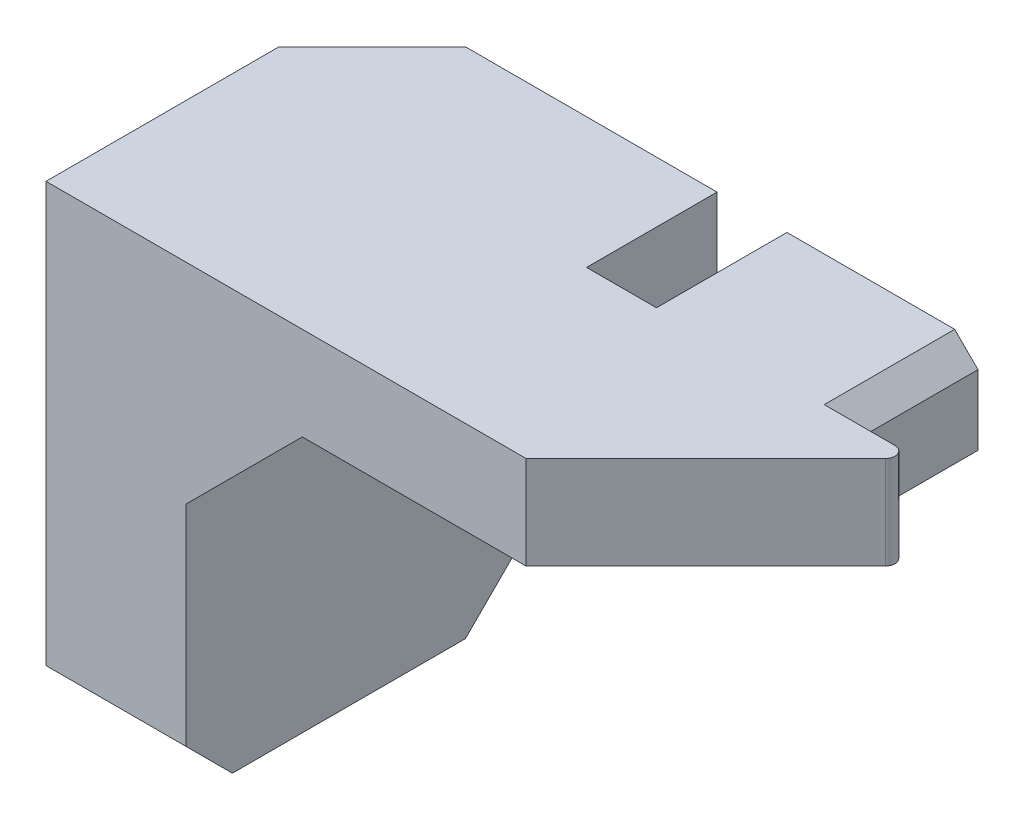
from build123d import *

# Parameters (mm, degrees)
BOSS_EXTRUDE1_DEPTH = 17.78
SKETCH4_W           = 2.54
SKETCH4_H           = 7.112
CUT_EXTRUDE2_DEPTH  = 6.08
CUT_EXTRUDE1_DEPTH  = 5.08
CHAMFER3_SIZE       = 2.54
FILLET2_R           = 0.508
CHAMFER4_SIZE       = 1.27


with BuildPart() as part:
    # Sketch1 → Boss-Extrude1 (new body)
    with BuildSketch(Plane.XY):
        Polygon((0, 0), (0, 25.4), (43.18, 25.4), (43.18, 20.32), (13.97, 20.32), (7.62, 13.97), (7.62, 0), align=None)
    extrude(amount=BOSS_EXTRUDE1_DEPTH)

    # Sketch4 → Cut-Extrude2 (cut, through all)
    with BuildSketch(Plane.XZ.offset(-20.32)):
        with Locations((20.066, 3.556)):
            Rectangle(SKETCH4_W, SKETCH4_H)
        Polygon((33.02, 0), (33.02, 7.112), (36.83, 7.112), (26.162, 17.78), (43.18, 17.78), (43.18, 0), align=None)
    extrude(amount=-CUT_EXTRUDE2_DEPTH, mode=Mode.SUBTRACT)

    # Sketch3 → Cut-Extrude1 (cut)
    with BuildSketch(Plane(origin=(0, 25.4, 0), x_dir=(1, 0, 0), z_dir=(0, 1, 0))):
        Polygon((0, 0), (0, -5.08), (5.08, 0), align=None)
    extrude(amount=-CUT_EXTRUDE1_DEPTH, mode=Mode.SUBTRACT)

    # Chamfer3
    chamfer3_edges = [part.edges().sort_by_distance(p)[0] for p in [
        (3.81, 0, 0),
        (3.81, 0, 17.78),
    ]]
    chamfer(chamfer3_edges, length=CHAMFER3_SIZE)

    # Fillet2
    fillet2_edges = [part.edges().sort_by_distance(p)[0] for p in [
        (36.83, 22.86, 7.112),
    ]]
    fillet(fillet2_edges, radius=FILLET2_R)

    # Chamfer4
    chamfer4_edges = [part.edges().sort_by_distance(p)[0] for p in [
        (21.336, 25.4, 3.556),
        (33.02, 25.4, 3.556),
    ]]
    chamfer(chamfer4_edges, length=CHAMFER4_SIZE)


solid = part.part
